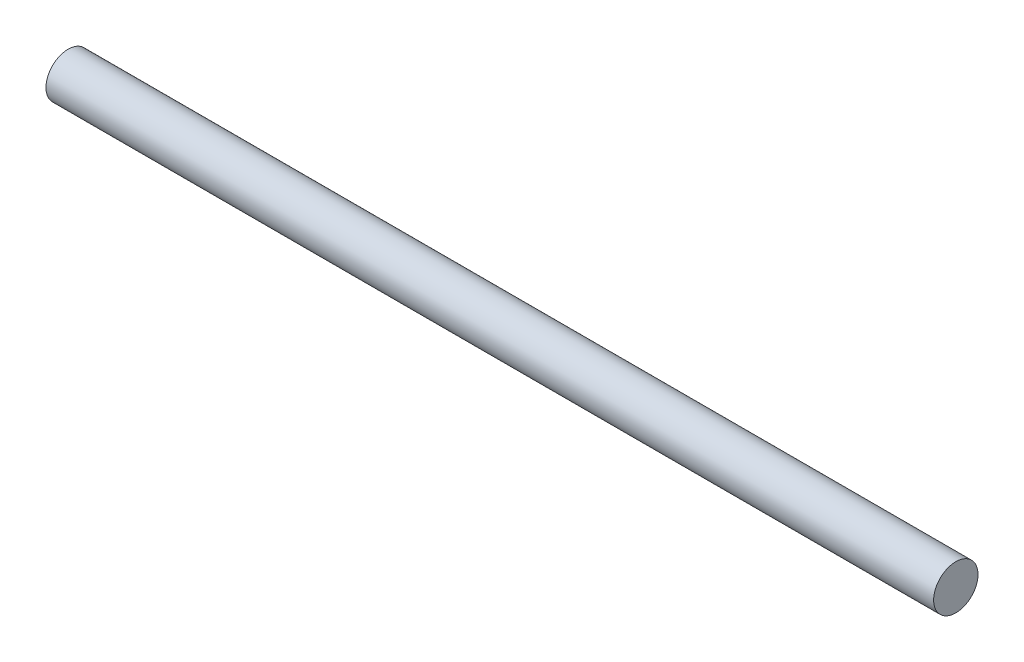
from build123d import *

# Parameters (mm, degrees)
SKETCH1_R           = 2
BOSS_EXTRUDE1_DEPTH = 40


with BuildPart() as part:
    # Sketch1 → Boss-Extrude1 (new body, symmetric)
    with BuildSketch(Plane(origin=(0, 0, 0), x_dir=(0, 0, -1), z_dir=(1, 0, 0))):
        Circle(SKETCH1_R)
    extrude(amount=BOSS_EXTRUDE1_DEPTH, both=True)


solid = part.part
